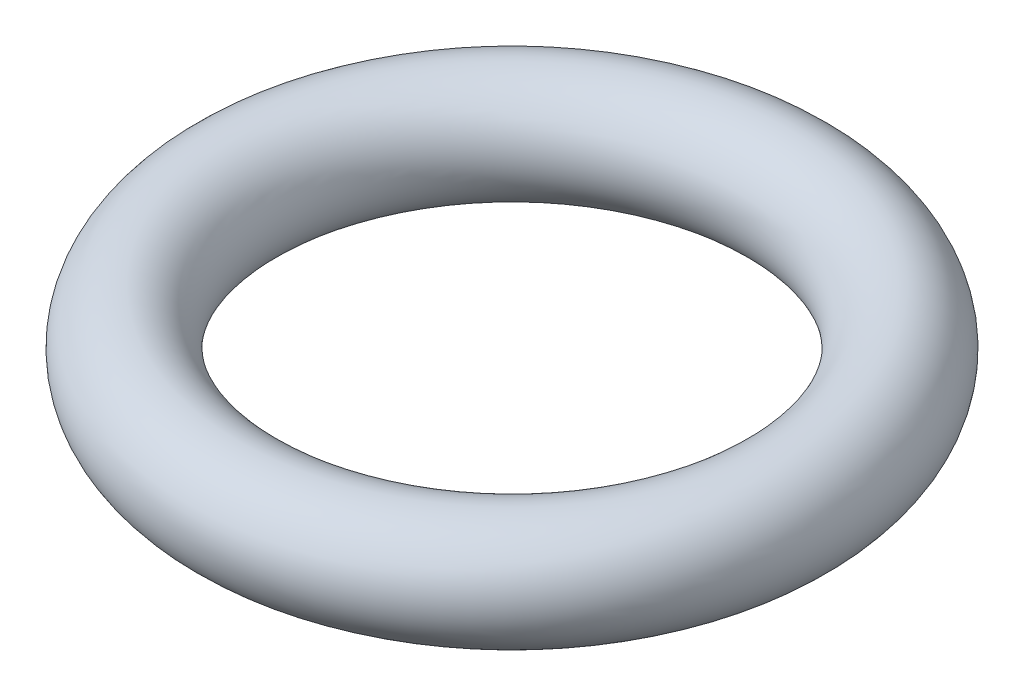
from build123d import *

# Parameters (mm, degrees)
SKETCH_1_R = 2


with BuildPart() as part:
    # 草图1 → 旋转1 (revolve)
    with BuildSketch(Plane.XY):
        with Locations((9.952351272, 0)):
            Circle(SKETCH_1_R)
    revolve(axis=Axis((0, 0, 0), (0, 1, 0)))


solid = part.part
